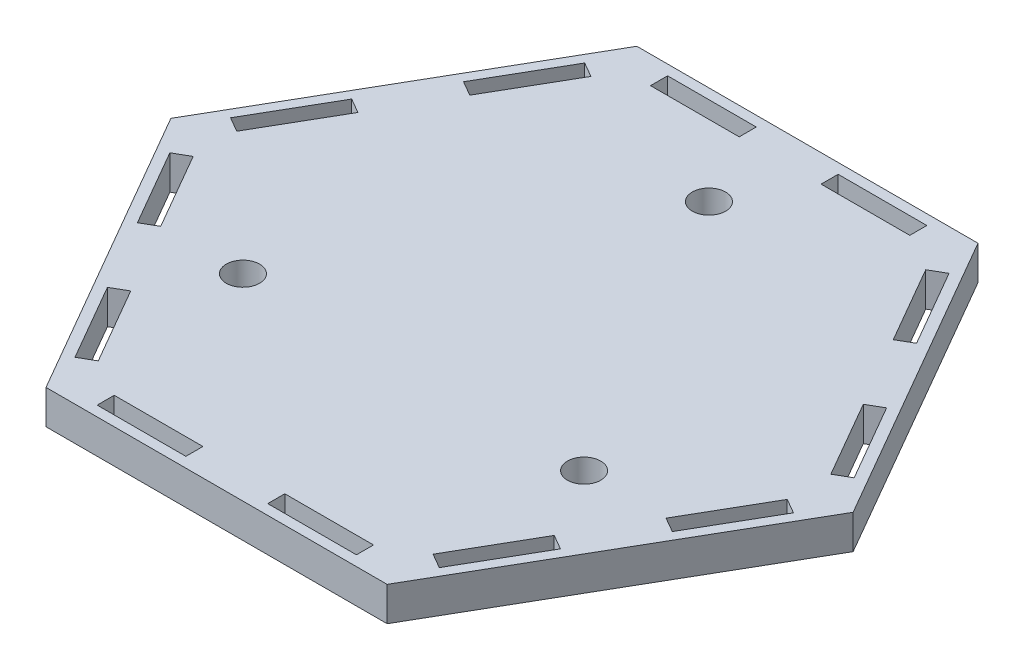
from build123d import *

# Parameters (mm, degrees)
BOSS_EXTRUDE1_DEPTH = 6.35
SKETCH2_R           = 3.0988
SKETCH2_W           = 16.51
SKETCH2_H           = 3.175
CUT_EXTRUDE1_DEPTH  = 7.35


with BuildPart() as part:
    # Sketch1 → Boss-Extrude1 (new body)
    with BuildSketch(Plane(origin=(0, 0, 0), x_dir=(1, 0, 0), z_dir=(0, 1, 0))):
        Polygon((-63.5, 0), (-31.75, -54.99261314), (31.75, -54.99261314), (63.5, 0), (31.75, 54.99261314), (-31.75, 54.99261314), align=None)
    extrude(amount=BOSS_EXTRUDE1_DEPTH)

    # Sketch2 → Cut-Extrude1 (cut, through all)
    with BuildSketch(Plane(origin=(0, 6.35, 0), x_dir=(1, 0, 0), z_dir=(0, 1, 0))):
        with Locations((-31.75, -18.330871047)):
            Circle(SKETCH2_R)
        with Locations((0, 36.661742094)):
            Circle(SKETCH2_R)
        with Locations((31.75, -18.330871047)):
            Circle(SKETCH2_R)
        Polygon((-55.290590949, -4.059113577), (-58.040221606, -5.646613577), (-49.785221606, -19.944692993), (-47.035590949, -18.357192993), align=None)
        Polygon((-31.160590949, -45.853499563), (-33.910221606, -47.440999563), (-42.165221606, -33.142920147), (-39.415590949, -31.555420147), align=None)
        Polygon((-31.160590949, 45.853499563), (-33.910221606, 47.440999563), (-42.165221606, 33.142920147), (-39.415590949, 31.555420147), align=None)
        Polygon((-49.785221606, 19.944692993), (-47.035590949, 18.357192993), (-55.290590949, 4.059113577), (-58.040221606, 5.646613577), align=None)
        with Locations((15.875, 51.50011314)):
            Rectangle(SKETCH2_W, SKETCH2_H)
        with Locations((-15.875, 51.50011314)):
            Rectangle(SKETCH2_W, SKETCH2_H)
        Polygon((55.290590949, 4.059113577), (58.040221606, 5.646613577), (49.785221606, 19.944692993), (47.035590949, 18.357192993), align=None)
        Polygon((42.165221606, 33.142920147), (39.415590949, 31.555420147), (31.160590949, 45.853499563), (33.910221606, 47.440999563), align=None)
        Polygon((31.160590949, -45.853499563), (33.910221606, -47.440999563), (42.165221606, -33.142920147), (39.415590949, -31.555420147), align=None)
        Polygon((49.785221606, -19.944692993), (47.035590949, -18.357192993), (55.290590949, -4.059113577), (58.040221606, -5.646613577), align=None)
        with Locations((-15.875, -51.50011314)):
            Rectangle(SKETCH2_W, SKETCH2_H)
        with Locations((15.875, -51.50011314)):
            Rectangle(SKETCH2_W, SKETCH2_H)
    extrude(amount=-CUT_EXTRUDE1_DEPTH, mode=Mode.SUBTRACT)


solid = part.part
